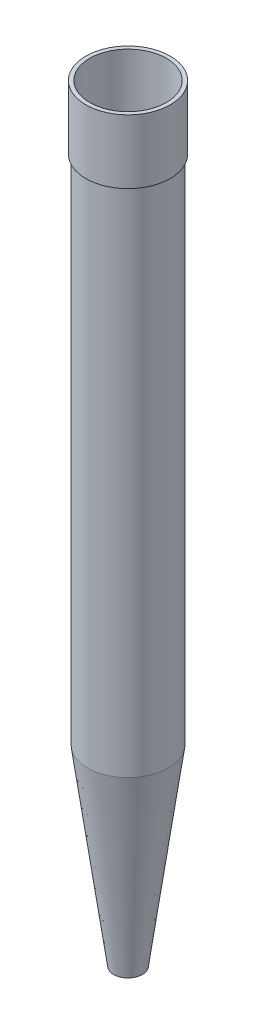
from build123d import *


with BuildPart() as part:
    # Sketch1 → Revolve1 (revolve)
    with BuildSketch(Plane.XY):
        Polygon((19.05, 0), (53.34, 254), (53.34, 931.333333333), (55.88, 931.333333333), (55.88, 1016), (50.8, 1016), (50.8, 254), (16.51, 0), align=None)
    revolve(axis=Axis((0, 37.971537268, 0), (0, 1, 0)))


solid = part.part
